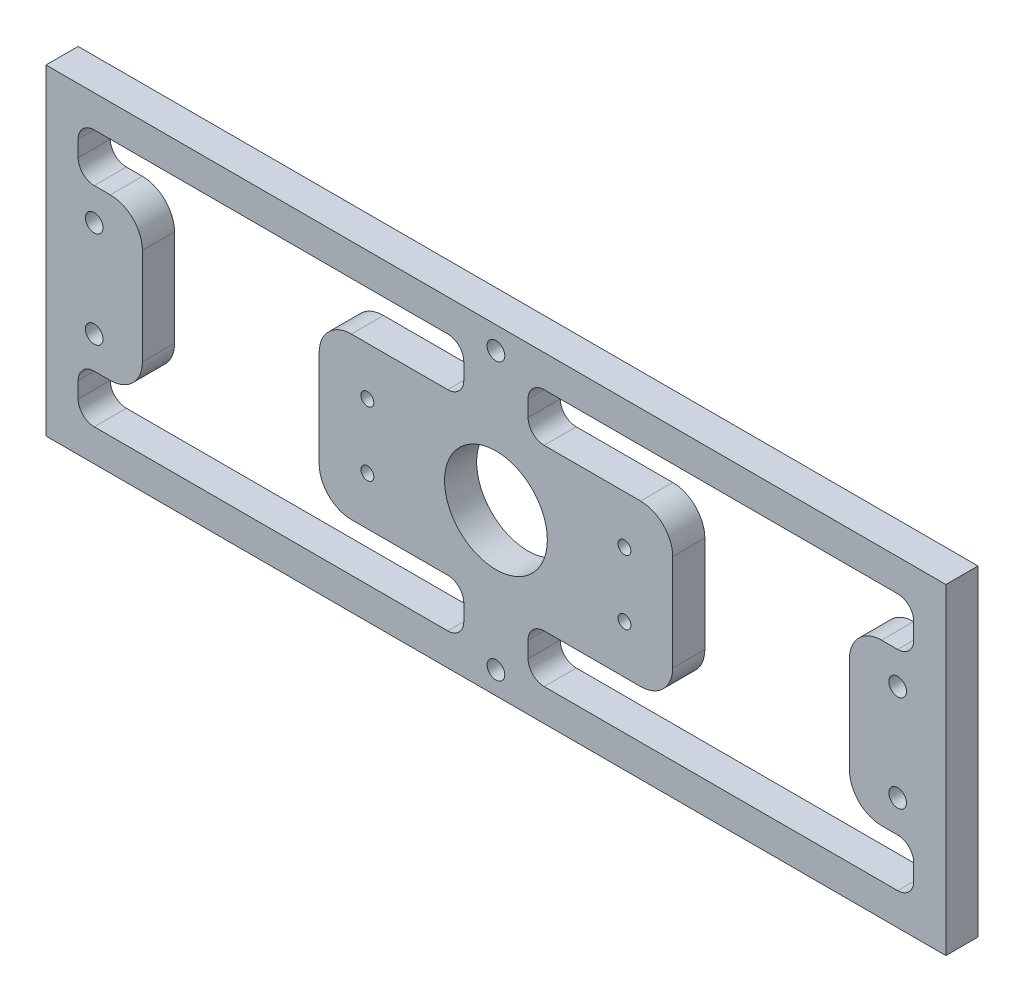
from build123d import *

# Parameters (mm, degrees)
SKETCH1_W           = 280
SKETCH1_H           = 100
SKETCH1_R           = 2
SKETCH1_R_2         = 16
BOSS_EXTRUDE1_DEPTH = 10
SKETCH2_R           = 2.75
CUT_EXTRUDE1_DEPTH  = 11
SKETCH3_R           = 4.5
CUT_EXTRUDE2_DEPTH  = 5
CUT_EXTRUDE3_DEPTH  = 11
FILLET1_R           = 10
FILLET2_R           = 5
SKETCH5_R           = 2.75
CUT_EXTRUDE4_DEPTH  = 11
SKETCH6_R           = 4.5
CUT_EXTRUDE5_DEPTH  = 5


with BuildPart() as part:
    # Sketch1 → Boss-Extrude1 (new body)
    with BuildSketch(Plane.XY):
        with Locations((140, 50)):
            Rectangle(SKETCH1_W, SKETCH1_H)
        with Locations((180, 60)):
            Circle(SKETCH1_R, mode=Mode.SUBTRACT)
        with Locations((180, 40)):
            Circle(SKETCH1_R, mode=Mode.SUBTRACT)
        with Locations((100, 60)):
            Circle(SKETCH1_R, mode=Mode.SUBTRACT)
        with Locations((100, 40)):
            Circle(SKETCH1_R, mode=Mode.SUBTRACT)
        with Locations((140, 50)):
            Circle(SKETCH1_R_2, mode=Mode.SUBTRACT)
    extrude(amount=BOSS_EXTRUDE1_DEPTH)

    # Sketch2 → Cut-Extrude1 (cut, through all)
    with BuildSketch(Plane(origin=(0, 0, 0), x_dir=(-1, 0, 0), z_dir=(0, 0, -1))):
        with Locations((-15, 35)):
            Circle(SKETCH2_R)
        with Locations((-15, 65)):
            Circle(SKETCH2_R)
        with Locations((-265, 35)):
            Circle(SKETCH2_R)
        with Locations((-265, 65)):
            Circle(SKETCH2_R)
    extrude(amount=-CUT_EXTRUDE1_DEPTH, mode=Mode.SUBTRACT)

    # Sketch3 → Cut-Extrude2 (cut)
    with BuildSketch(Plane(origin=(0, 0, 0), x_dir=(-1, 0, 0), z_dir=(0, 0, -1))):
        with Locations((-265, 65)):
            Circle(SKETCH3_R)
        with Locations((-265, 35)):
            Circle(SKETCH3_R)
        with Locations((-15, 35)):
            Circle(SKETCH3_R)
        with Locations((-15, 65)):
            Circle(SKETCH3_R)
    extrude(amount=-CUT_EXTRUDE2_DEPTH, mode=Mode.SUBTRACT)

    # Sketch4 → Cut-Extrude3 (cut, through all)
    with BuildSketch(Plane.XY.offset(10)):
        Polygon((10, 25), (30, 25), (30, 75), (10, 75), (10, 90), (130, 90), (130, 75), (85, 75), (85, 25), (130, 25), (130, 10), (10, 10), align=None)
        Polygon((150, 90), (150, 75), (195, 75), (195, 25), (150, 25), (150, 10), (270, 10), (270, 25), (250, 25), (250, 75), (270, 75), (270, 90), align=None)
    extrude(amount=-CUT_EXTRUDE3_DEPTH, mode=Mode.SUBTRACT)

    # Fillet1
    fillet1_edges = [part.edges().sort_by_distance(p)[0] for p in [
        (250, 75, 5),
        (250, 25, 5),
        (195, 25, 5),
        (195, 75, 5),
        (30, 25, 5),
        (30, 75, 5),
        (85, 75, 5),
        (85, 25, 5),
    ]]
    fillet(fillet1_edges, radius=FILLET1_R)

    # Fillet2
    fillet2_edges = [part.edges().sort_by_distance(p)[0] for p in [
        (150, 90, 5),
        (270, 90, 5),
        (270, 75, 5),
        (270, 25, 5),
        (270, 10, 5),
        (150, 10, 5),
        (150, 25, 5),
        (150, 75, 5),
        (10, 10, 5),
        (10, 25, 5),
        (10, 75, 5),
        (10, 90, 5),
        (130, 90, 5),
        (130, 75, 5),
        (130, 25, 5),
        (130, 10, 5),
    ]]
    fillet(fillet2_edges, radius=FILLET2_R)

    # Sketch5 → Cut-Extrude4 (cut, through all)
    with BuildSketch(Plane.XY.offset(10)):
        with Locations((140, 7)):
            Circle(SKETCH5_R)
        with Locations((140, 93)):
            Circle(SKETCH5_R)
    extrude(amount=-CUT_EXTRUDE4_DEPTH, mode=Mode.SUBTRACT)

    # Sketch6 → Cut-Extrude5 (cut)
    with BuildSketch(Plane(origin=(0, 0, 0), x_dir=(-1, 0, 0), z_dir=(0, 0, -1))):
        with Locations((-140, 7)):
            Circle(SKETCH6_R)
        with Locations((-140, 93)):
            Circle(SKETCH6_R)
    extrude(amount=-CUT_EXTRUDE5_DEPTH, mode=Mode.SUBTRACT)


solid = part.part
